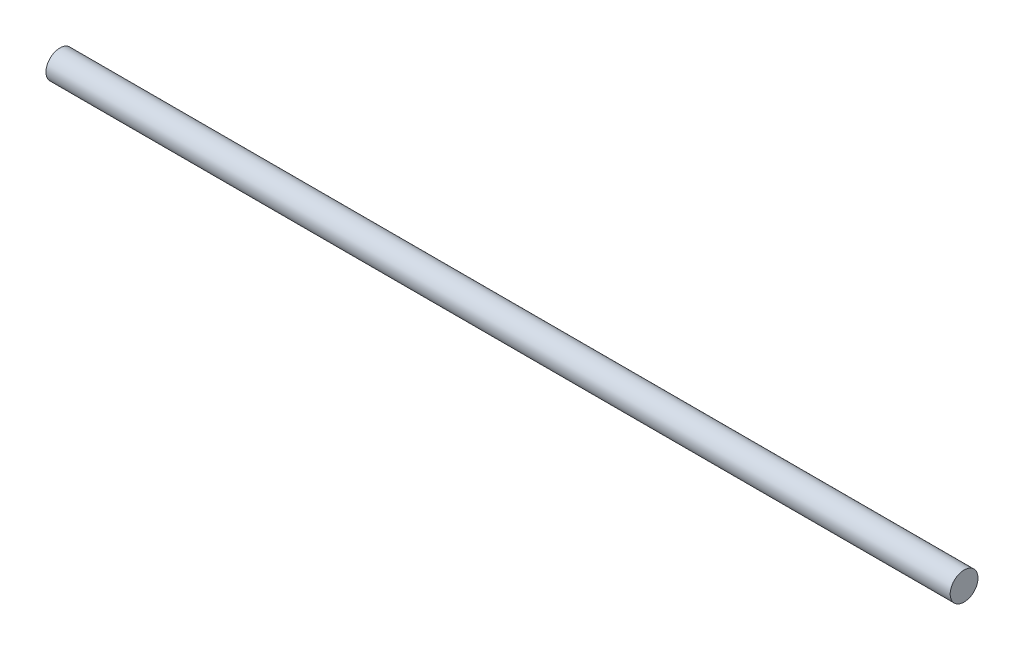
from build123d import *

# Parameters (mm, degrees)
SKETCH1_R           = 1
BOSS_EXTRUDE1_DEPTH = 32.5


with BuildPart() as part:
    # Sketch1 → Boss-Extrude1 (new body, symmetric)
    with BuildSketch(Plane(origin=(0, 0, 0), x_dir=(0, 0, -1), z_dir=(1, 0, 0))):
        Circle(SKETCH1_R)
    extrude(amount=BOSS_EXTRUDE1_DEPTH, both=True)


solid = part.part
